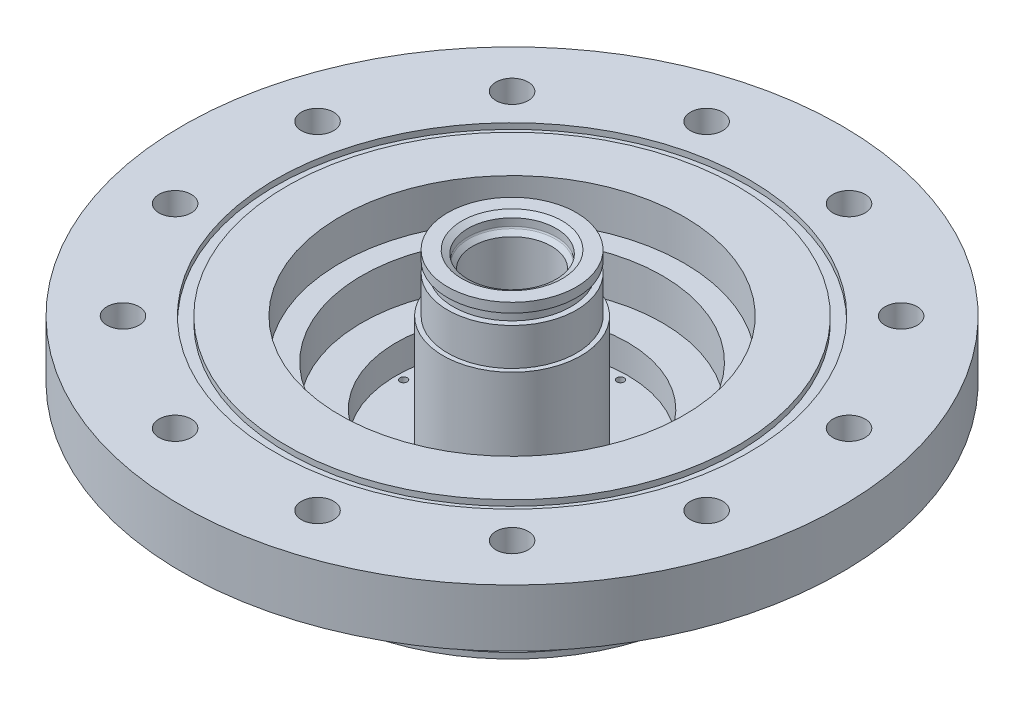
from build123d import *

# Parameters (mm, degrees)
OUTER_FUEL_ORIFICE_CUT_REACH               = 121.518
SKETCH_OUTER_FUEL_DIAMATER_R               = 0.59563
OUTER_FUEL_ORIFICE_CUT_DIRECTION_2_REACH   = 121.518
OUTER_FUEL_COUNT                           = 8
FC_ORIFICE_CUT_TOP_HALF_REACH              = 124.379
FC_DIAMATER_R                              = 0.3175
FC_ORIFICE_CUT_TOP_HALF_DIRECTION_2_REACH  = 124.379
FC_TOP_HALF_COUNT                          = 8
INNER_FUEL_ORIFICE_CUT_REACH               = 122.332
INNER_FUEL_DIAMETER_R                      = 0.4572
INNER_FUEL_ORIFICE_CUT_DIRECTION_2_REACH   = 122.332
INNER_FUEL_COUNT                           = 8
LOX_ORIFICES_CUT_REACH                     = 115.993
LOX_DIAMETER_AND_LOCATION_R                = 0.80645
LOX_COUNT                                  = 8
FUEL_CHANNEL_CUT_REACH                     = 137.474
FUEL_CHANNEL_DIAMETER_R                    = 0.889
FUEL_CHANNEL_CUT_DIRECTION_2_DEPTH         = 12.7
FUEL_CHANNEL_COUNT                         = 24
ASSEMBLY_BOLT_CUT_REACH                    = 111.224
ASSEMBLY_BOLT_HOLE_DIAMETER_AND_LOCATION_R = 3.571875
ASSEMBLY_BOLTS_COUNT                       = 12


with BuildPart() as part:
    # Injector Profile → Injector Body (revolve)
    with BuildSketch(Plane.XY):
        Polygon((-8.7122, 48.26), (-8.7122, 4.9022), (0, 4.9022), (0, 0), (-42.8371, 0), (-42.8371, 1.27), (-41.5925, 1.27), (-41.5925, 3.6322), (-42.8371, 3.6322), (-42.8371, 4.9022), (-32.6771, 4.9022), (-32.6771, 7.4422), (-42.8371, 12.618978567), (-42.8371, 22.86), (-73.025, 22.86), (-73.025, 35.56), (-52.4383, 35.56), (-52.4383, 34.29), (-49.8729, 34.29), (-49.8729, 35.56), (-38.1, 35.56), (-38.1, 26.67), (-33.2818704, 26.67), (-33.2818704, 17.6403), (-25.6618704, 17.6403), (-25.6618704, 11.2903), (-15.2781, 11.2903), (-15.2781, 35.56), (-14.2621, 35.56), (-14.2621, 43.815), (-13.0175, 43.815), (-13.0175, 46.1772), (-14.2621, 46.1772), (-14.2621, 48.26), align=None)
    revolve(axis=Axis((0, 0, 0), (0, 1, 0)))

    # Sketch - Outer Fuel Diamater → Outer Fuel Orifice Cut (cut, up to next)
    with BuildSketch(Plane(origin=(-15.875, 15.875, 0), x_dir=(0, 0, -1), z_dir=(0.7071067811865487, -0.7071067811865464, 0)), mode=Mode.PRIVATE) as outer_fuel_orifice_cut_sk1:
        with Locations((0, -22.450640303)):
            Circle(SKETCH_OUTER_FUEL_DIAMATER_R)
    outer_fuel_orifice_cut_tool1 = extrude(outer_fuel_orifice_cut_sk1.sketch, amount=-OUTER_FUEL_ORIFICE_CUT_REACH, mode=Mode.PRIVATE) & part.part
    outer_fuel_orifice_cut = outer_fuel_orifice_cut_tool1.solids().sort_by_distance((-31.75, 0, 0))[0]
    add(outer_fuel_orifice_cut, mode=Mode.SUBTRACT)

    # Sketch - Outer Fuel Diamater → Outer Fuel Orifice Cut direction 2 (cut, up to next)
    with BuildSketch(Plane(origin=(-15.875, 15.875, 0), x_dir=(0, 0, -1), z_dir=(0.7071067811865487, -0.7071067811865464, 0)), mode=Mode.PRIVATE) as outer_fuel_orifice_cut_direction_2_sk1:
        with Locations((0, -22.450640303)):
            Circle(SKETCH_OUTER_FUEL_DIAMATER_R)
    outer_fuel_orifice_cut_direction_2_tool1 = extrude(outer_fuel_orifice_cut_direction_2_sk1.sketch, amount=OUTER_FUEL_ORIFICE_CUT_DIRECTION_2_REACH, mode=Mode.PRIVATE) & part.part
    outer_fuel_orifice_cut_direction_2 = outer_fuel_orifice_cut_direction_2_tool1.solids().sort_by_distance((-31.75, 0, 0))[0]
    add(outer_fuel_orifice_cut_direction_2, mode=Mode.SUBTRACT)

    # Outer Fuel: Outer Fuel Orifice Cut, Outer Fuel Orifice Cut direction 2 ×8 about axis
    outer_fuel_axis = Axis((0, -222.253100373, 0), (0, 1, 0))
    add([outer_fuel_orifice_cut.rotate(outer_fuel_axis, i * 360 / OUTER_FUEL_COUNT) for i in range(1, OUTER_FUEL_COUNT)], mode=Mode.SUBTRACT)
    add([outer_fuel_orifice_cut_direction_2.rotate(outer_fuel_axis, i * 360 / OUTER_FUEL_COUNT) for i in range(1, OUTER_FUEL_COUNT)], mode=Mode.SUBTRACT)

    # FC Diamater → FC Orifice Cut _Top Half (cut, up to next)
    with BuildSketch(Plane(origin=(-3.473325533, -11.570552691, -1.438698542), x_dir=(0.9577200070306089, -0.2876972976295448, 0.0016288247135752404), z_dir=(-0.28549447630117, -0.9510565162951534, -0.11825568406654888)), mode=Mode.PRIVATE) as fc_orifice_cut_top_half_sk1:
        with Locations((-34.859821485, -13.666682578)):
            Circle(FC_DIAMATER_R)
    fc_orifice_cut_top_half_tool1 = extrude(fc_orifice_cut_top_half_sk1.sketch, amount=-FC_ORIFICE_CUT_TOP_HALF_REACH, mode=Mode.PRIVATE) & part.part
    fc_orifice_cut_top_half = fc_orifice_cut_top_half_tool1.solids().sort_by_distance((-36.373137, 0, -15.066247))[0]
    add(fc_orifice_cut_top_half, mode=Mode.SUBTRACT)

    # FC Diamater → FC Orifice Cut _Top Half direction 2 (cut, up to next)
    with BuildSketch(Plane(origin=(-3.473325533, -11.570552691, -1.438698542), x_dir=(0.9577200070306089, -0.2876972976295448, 0.0016288247135752404), z_dir=(-0.28549447630117, -0.9510565162951534, -0.11825568406654888)), mode=Mode.PRIVATE) as fc_orifice_cut_top_half_direction_2_sk1:
        with Locations((-34.859821485, -13.666682578)):
            Circle(FC_DIAMATER_R)
    fc_orifice_cut_top_half_direction_2_tool1 = extrude(fc_orifice_cut_top_half_direction_2_sk1.sketch, amount=FC_ORIFICE_CUT_TOP_HALF_DIRECTION_2_REACH, mode=Mode.PRIVATE) & part.part
    fc_orifice_cut_top_half_direction_2 = fc_orifice_cut_top_half_direction_2_tool1.solids().sort_by_distance((-36.373137, 0, -15.066247))[0]
    add(fc_orifice_cut_top_half_direction_2, mode=Mode.SUBTRACT)

    # FC _Top Half: FC Orifice Cut _Top Half, FC Orifice Cut _Top Half direction 2 ×8 about axis
    fc_top_half_axis = Axis((0, -222.253100373, 0), (0, 1, 0))
    add([fc_orifice_cut_top_half.rotate(fc_top_half_axis, i * 360 / FC_TOP_HALF_COUNT) for i in range(1, FC_TOP_HALF_COUNT)], mode=Mode.SUBTRACT)
    add([fc_orifice_cut_top_half_direction_2.rotate(fc_top_half_axis, i * 360 / FC_TOP_HALF_COUNT) for i in range(1, FC_TOP_HALF_COUNT)], mode=Mode.SUBTRACT)

    # Inner Fuel Diameter → Inner Fuel Orifice Cut (cut, up to next)
    with BuildSketch(Plane(origin=(-5.842, -5.842, 0), x_dir=(0, 0, 1), z_dir=(-0.7071067811865488, -0.7071067811865465, 0)), mode=Mode.PRIVATE) as inner_fuel_orifice_cut_sk1:
        with Locations((0, 8.261835631)):
            Circle(INNER_FUEL_DIAMETER_R)
    inner_fuel_orifice_cut_tool1 = extrude(inner_fuel_orifice_cut_sk1.sketch, amount=-INNER_FUEL_ORIFICE_CUT_REACH, mode=Mode.PRIVATE) & part.part
    inner_fuel_orifice_cut = inner_fuel_orifice_cut_tool1.solids().sort_by_distance((-11.684, 0, 0))[0]
    add(inner_fuel_orifice_cut, mode=Mode.SUBTRACT)

    # Inner Fuel Diameter → Inner Fuel Orifice Cut direction 2 (cut, up to next)
    with BuildSketch(Plane(origin=(-5.842, -5.842, 0), x_dir=(0, 0, 1), z_dir=(-0.7071067811865488, -0.7071067811865465, 0)), mode=Mode.PRIVATE) as inner_fuel_orifice_cut_direction_2_sk1:
        with Locations((0, 8.261835631)):
            Circle(INNER_FUEL_DIAMETER_R)
    inner_fuel_orifice_cut_direction_2_tool1 = extrude(inner_fuel_orifice_cut_direction_2_sk1.sketch, amount=INNER_FUEL_ORIFICE_CUT_DIRECTION_2_REACH, mode=Mode.PRIVATE) & part.part
    inner_fuel_orifice_cut_direction_2 = inner_fuel_orifice_cut_direction_2_tool1.solids().sort_by_distance((-11.684, 0, 0))[0]
    add(inner_fuel_orifice_cut_direction_2, mode=Mode.SUBTRACT)

    # Inner Fuel: Inner Fuel Orifice Cut, Inner Fuel Orifice Cut direction 2 ×8 about axis
    inner_fuel_axis = Axis((0, -222.253100373, 0), (0, 1, 0))
    add([inner_fuel_orifice_cut.rotate(inner_fuel_axis, i * 360 / INNER_FUEL_COUNT) for i in range(1, INNER_FUEL_COUNT)], mode=Mode.SUBTRACT)
    add([inner_fuel_orifice_cut_direction_2.rotate(inner_fuel_axis, i * 360 / INNER_FUEL_COUNT) for i in range(1, INNER_FUEL_COUNT)], mode=Mode.SUBTRACT)

    # LOX diameter and Location → LOX Orifices Cut (cut, up to next)
    with BuildSketch(Plane.XZ, mode=Mode.PRIVATE) as lox_orifices_cut_sk1:
        with Locations((-24.0284, 0)):
            Circle(LOX_DIAMETER_AND_LOCATION_R)
    lox_orifices_cut_tool1 = extrude(lox_orifices_cut_sk1.sketch, amount=-LOX_ORIFICES_CUT_REACH, mode=Mode.PRIVATE) & part.part
    # LOX diameter and Location → LOX Orifices Cut (cut, up to next)
    with BuildSketch(Plane.XZ, mode=Mode.PRIVATE) as lox_orifices_cut_sk2:
        with Locations((-19.4056, 0)):
            Circle(LOX_DIAMETER_AND_LOCATION_R)
    lox_orifices_cut_tool2 = extrude(lox_orifices_cut_sk2.sketch, amount=-LOX_ORIFICES_CUT_REACH, mode=Mode.PRIVATE) & part.part
    lox_orifices_cut_1 = lox_orifices_cut_tool1.solids().sort_by_distance((-24.0284, 0, 0))[0]
    add(lox_orifices_cut_1, mode=Mode.SUBTRACT)
    lox_orifices_cut_2 = lox_orifices_cut_tool2.solids().sort_by_distance((-19.4056, 0, 0))[0]
    add(lox_orifices_cut_2, mode=Mode.SUBTRACT)
    lox_orifices_cut = lox_orifices_cut_1 + lox_orifices_cut_2  # LOX Orifices Cut as one shape, for the pattern or mirror that repeats it

    # LOX: LOX Orifices Cut ×8 about axis
    lox_axis = Axis((0, -222.253100373, 0), (0, 1, 0))
    for i in range(1, LOX_COUNT):
        add(lox_orifices_cut.rotate(lox_axis, i * 360 / LOX_COUNT), mode=Mode.SUBTRACT)

    # Fuel Channel Diameter → Fuel Channel Cut (cut, up to next)
    with BuildSketch(Plane(origin=(-27.700969427, 0, -3.646901811), x_dir=(0.13052619222004844, 0, -0.9914448613738109), z_dir=(0.9914448613738109, 0, 0.13052619222004844)), mode=Mode.PRIVATE) as fuel_channel_cut_sk1:
        with Locations((0, 6.0452)):
            Circle(FUEL_CHANNEL_DIAMETER_R)
    fuel_channel_cut_tool1 = extrude(fuel_channel_cut_sk1.sketch, amount=FUEL_CHANNEL_CUT_REACH, mode=Mode.PRIVATE) & part.part
    fuel_channel_cut = fuel_channel_cut_tool1.solids().sort_by_distance((-27.700969, 6.0452, -3.646902))[0]
    add(fuel_channel_cut, mode=Mode.SUBTRACT)

    # Fuel Channel Diameter → Fuel Channel Cut direction 2 (cut)
    with BuildSketch(Plane(origin=(-27.700969427, 0, -3.646901811), x_dir=(0.13052619222004844, 0, -0.9914448613738109), z_dir=(0.9914448613738109, 0, 0.13052619222004844))):
        with Locations((0, 6.0452)):
            Circle(FUEL_CHANNEL_DIAMETER_R)
    fuel_channel_cut_direction_2 = extrude(amount=-FUEL_CHANNEL_CUT_DIRECTION_2_DEPTH, mode=Mode.SUBTRACT)

    # Fuel Channel: Fuel Channel Cut, Fuel Channel Cut direction 2 ×24 about axis
    fuel_channel_axis = Axis((0, -222.253100373, 0), (0, 1, 0))
    add([fuel_channel_cut.rotate(fuel_channel_axis, i * 360 / FUEL_CHANNEL_COUNT) for i in range(1, FUEL_CHANNEL_COUNT)], mode=Mode.SUBTRACT)
    add([fuel_channel_cut_direction_2.rotate(fuel_channel_axis, i * 360 / FUEL_CHANNEL_COUNT) for i in range(1, FUEL_CHANNEL_COUNT)], mode=Mode.SUBTRACT)

    # Assembly Bolt Hole Diameter and Location → Assembly Bolt Cut (cut, up to next)
    with BuildSketch(Plane(origin=(0, 35.56, 0), x_dir=(1, 0, 0), z_dir=(0, 1, 0)), mode=Mode.PRIVATE) as assembly_bolt_cut_sk1:
        with Locations((-58.882838371, 15.777608989)):
            Circle(ASSEMBLY_BOLT_HOLE_DIAMETER_AND_LOCATION_R)
    assembly_bolt_cut_tool1 = extrude(assembly_bolt_cut_sk1.sketch, amount=-ASSEMBLY_BOLT_CUT_REACH, mode=Mode.PRIVATE) & part.part
    assembly_bolt_cut = assembly_bolt_cut_tool1.solids().sort_by_distance((-58.882838, 35.56, -15.777609))[0]
    add(assembly_bolt_cut, mode=Mode.SUBTRACT)

    # Assembly Bolts: Assembly Bolt Cut ×12 about axis
    assembly_bolts_axis = Axis((0, -222.253100373, 0), (0, 1, 0))
    for i in range(1, ASSEMBLY_BOLTS_COUNT):
        add(assembly_bolt_cut.rotate(assembly_bolts_axis, i * 360 / ASSEMBLY_BOLTS_COUNT), mode=Mode.SUBTRACT)

    # Sketch15 → Cut-Revolve1 (revolve, cut)
    with BuildSketch(Plane(origin=(0, 0, 0), x_dir=(0, 0, -1), z_dir=(1, 0, 0))):
        with BuildLine():
            Line((-8.7122, 48.26), (-11.1125, 48.26))
            Line((-11.1125, 48.26), (-9.7663, 47.482771068))
            Line((-9.7663, 47.482771068), (-9.7663, 45.8724))
            ThreePointArc((-9.7663, 45.8724), (-9.727630803, 45.677996816), (-9.617510245, 45.513189755))
            Line((-9.617510245, 45.513189755), (-8.7122, 44.60787951))
            Line((-8.7122, 44.60787951), (-8.7122, 48.26))
        make_face()
    revolve(axis=Axis((0, 48.26, 0), (0, -1, 0)), mode=Mode.SUBTRACT)


solid = part.part
